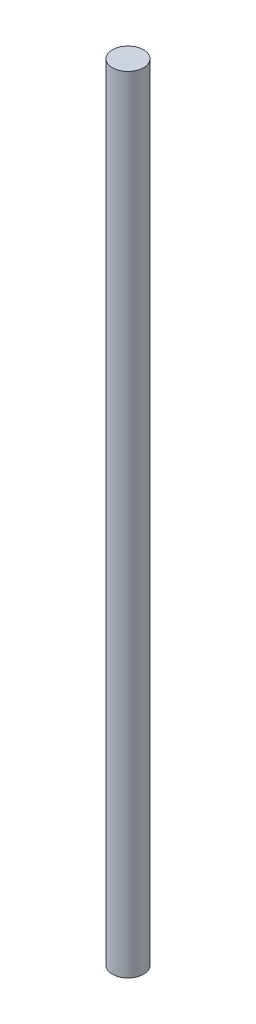
from build123d import *

# Parameters (mm, degrees)
SKETCH1_R           = 4
BOSS_EXTRUDE1_DEPTH = 100.7125


with BuildPart() as part:
    # Sketch1 → Boss-Extrude1 (new body, symmetric)
    with BuildSketch(Plane(origin=(0, 0, 0), x_dir=(1, 0, 0), z_dir=(0, 1, 0))):
        Circle(SKETCH1_R)
    extrude(amount=BOSS_EXTRUDE1_DEPTH, both=True)


solid = part.part
